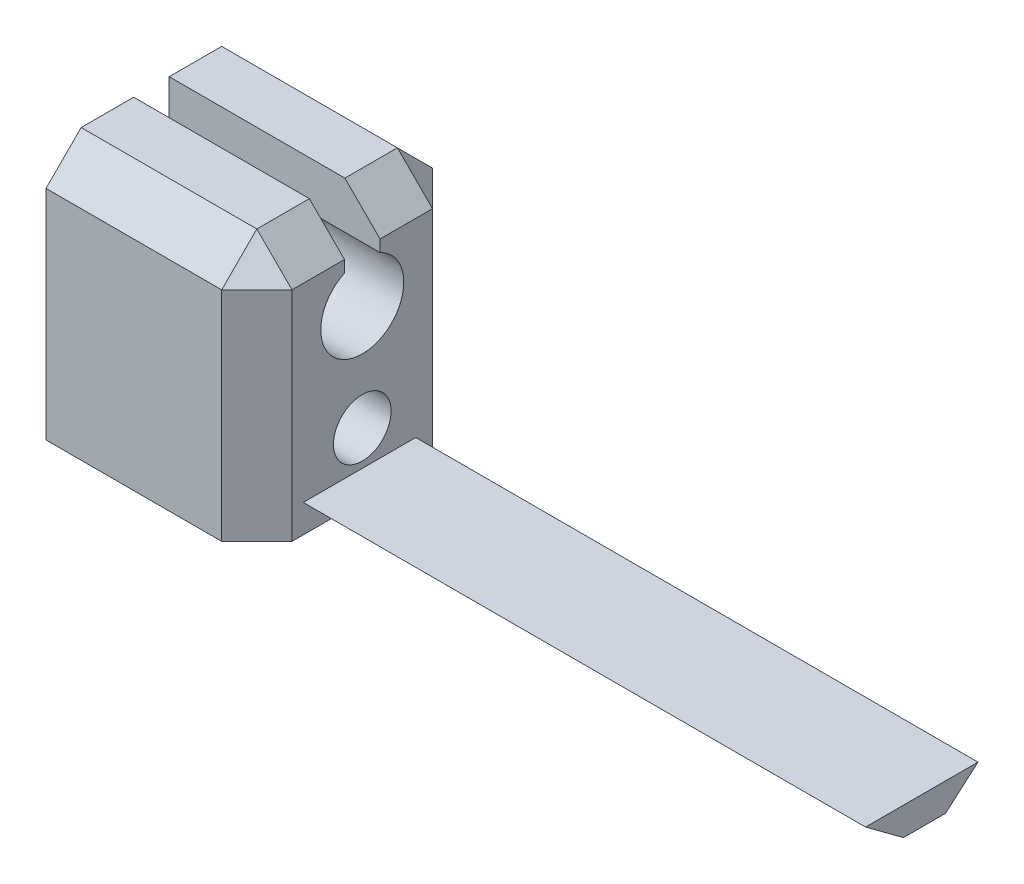
from build123d import *

# Parameters (mm, degrees)
SKETCH2_W               = 30
SKETCH2_H               = 30
BOSS_EXTRUDE1_DEPTH     = 36
BOSS_EXTRUDE2_DEPTH     = 80
SKETCH5_R               = 4.1
CUT_EXTRUDE1_DEPTH      = 80
CUT_EXTRUDE2_DEPTH      = 80
CUT_EXTRUDE2_DEPTH_BACK = 80
CHAMFER1_SIZE           = 5


with BuildPart() as part:
    # Sketch2 → Boss-Extrude1 (new body)
    with BuildSketch(Plane(origin=(0, 0, 0), x_dir=(1, 0, 0), z_dir=(0, 1, 0))):
        Rectangle(SKETCH2_W, SKETCH2_H)
    extrude(amount=BOSS_EXTRUDE1_DEPTH)

    # Sketch4 → Boss-Extrude2 (add)
    with BuildSketch(Plane(origin=(15, 0, 0), x_dir=(0, 0, -1), z_dir=(1, 0, 0))):
        Polygon((-8.392439038, 4), (-3, 0), (0, 0), (3, 0), (7.607560962, 4), align=None)
    extrude(amount=BOSS_EXTRUDE2_DEPTH)

    # Sketch5 → Cut-Extrude1 (cut)
    with BuildSketch(Plane(origin=(15, 0, 0), x_dir=(0, 0, -1), z_dir=(1, 0, 0))):
        with Locations((0, 9)):
            Circle(SKETCH5_R)
    extrude(amount=-CUT_EXTRUDE1_DEPTH, mode=Mode.SUBTRACT)

    # Sketch6 → Cut-Extrude2 (cut, two sides: drawn at the far end of the back side and taken through both)
    with BuildSketch(Plane(origin=(15, 0, 0), x_dir=(0, 0, -1), z_dir=(1, 0, 0)).offset(-CUT_EXTRUDE2_DEPTH_BACK)):
        with BuildLine():
            Line((2.528554435, 36.330541101), (-2.528554435, 36.330541101))
            Line((-2.528554435, 36.330541101), (-2.528554435, 29.330704688))
            ThreePointArc((-2.528554435, 29.330704688), (-5.755916854, 22.704075168), (0, 18.1))
            ThreePointArc((0, 18.1), (5.755916854, 22.704075168), (2.528554435, 29.330704688))
            Line((2.528554435, 29.330704688), (2.528554435, 36.330541101))
        make_face()
    extrude(amount=CUT_EXTRUDE2_DEPTH + CUT_EXTRUDE2_DEPTH_BACK, mode=Mode.SUBTRACT)

    # Chamfer1
    chamfer1_edges = [part.edges().sort_by_distance(p)[0] for p in [
        (15, 36, -8.764277217),
        (0, 36, -15),
        (15, 36, 8.764277217),
        (0, 36, 15),
        (15, 18, -15),
        (15, 18, 15),
    ]]
    chamfer(chamfer1_edges, length=CHAMFER1_SIZE)


solid = part.part
